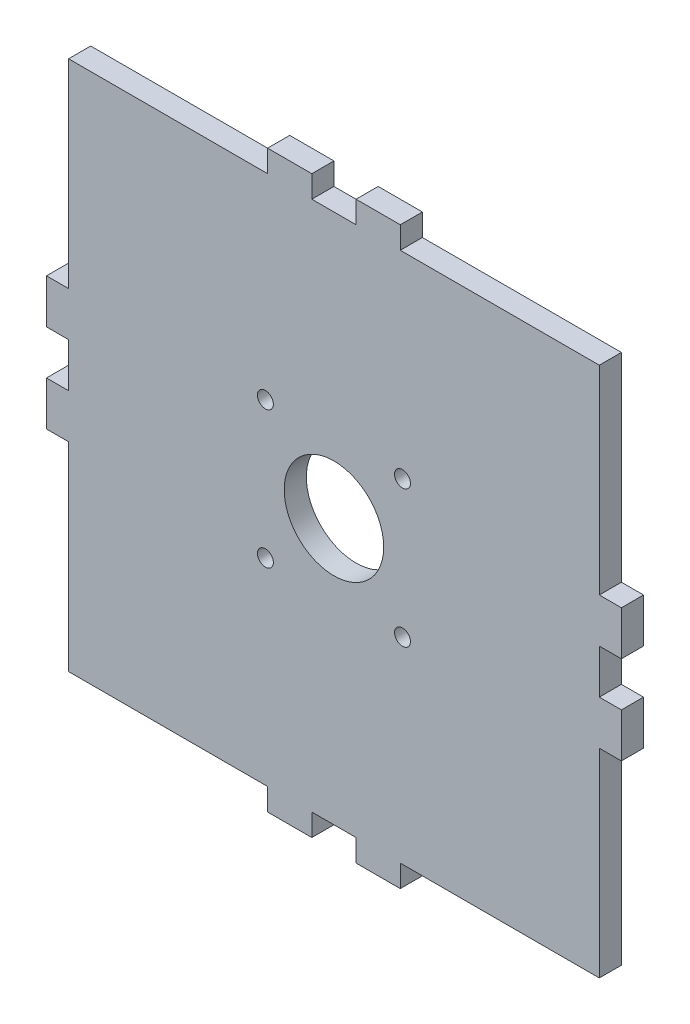
from build123d import *

# Parameters (mm, degrees)
SKETCH1_R           = 11.25
SKETCH1_R_2         = 1.8
BOSS_EXTRUDE1_DEPTH = 5


with BuildPart() as part:
    # Sketch1 → Boss-Extrude1 (new body)
    with BuildSketch(Plane.XY):
        Polygon((5, 60), (-5, 60), (-5, 65), (-15, 65), (-15, 60), (-60, 60), (-60, 15), (-65, 15), (-65, 5), (-60, 5), (-60, -5), (-65, -5), (-65, -15), (-60, -15), (-60, -60), (-15, -60), (-15, -65), (-5, -65), (-5, -60), (5, -60), (5, -65), (15, -65), (15, -60), (60, -60), (60, -15), (65, -15), (65, -5), (60, -5), (60, 5), (65, 5), (65, 15), (60, 15), (60, 60), (15, 60), (15, 65), (5, 65), align=None)
        Circle(SKETCH1_R, mode=Mode.SUBTRACT)
        with Locations((-15.5, 15.5)):
            Circle(SKETCH1_R_2, mode=Mode.SUBTRACT)
        with Locations((15.5, 15.5)):
            Circle(SKETCH1_R_2, mode=Mode.SUBTRACT)
        with Locations((15.5, -15.5)):
            Circle(SKETCH1_R_2, mode=Mode.SUBTRACT)
        with Locations((-15.5, -15.5)):
            Circle(SKETCH1_R_2, mode=Mode.SUBTRACT)
    extrude(amount=BOSS_EXTRUDE1_DEPTH)


solid = part.part
